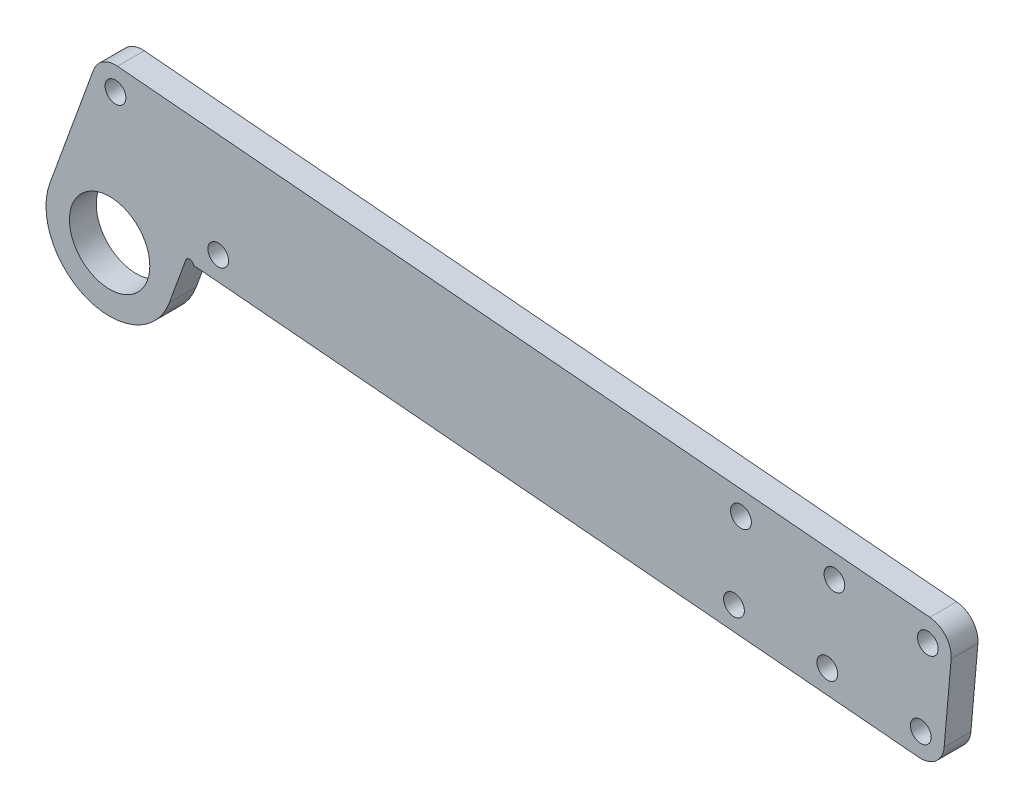
from build123d import *

# Parameters (mm, degrees)
SKETCH_1_R          = 6
EXTRUDE_1_DEPTH     = 2
SKETCH_2_R          = 1.55
SKETCH_2_R_2        = 0.6
CUT_EXTRUDE_1_DEPTH = 5
FILLET_1_R          = 3.5
CUT_EXTRUDE_2_DEPTH = 5
SKETCH_4_R          = 1.55
CUT_EXTRUDE_3_DEPTH = 5
FILLET_2_R          = 3.5


with BuildPart() as part:
    # 草图1 → 凸台-拉伸1 (new body, symmetric)
    with BuildSketch(Plane.XY):
        with BuildLine():
            Line((-8.927079897, 3.249191362), (-1.4961968, 23.665374879))
            Line((-1.4961968, 23.665374879), (160.827979556, 9.463849632))
            ThreePointArc((160.827979556, 9.463849632), (169.463849632, -0.827979556), (159.172020444, -9.463849632))
            Line((159.172020444, -9.463849632), (11.371578553, 3.467013498))
            Line((11.371578553, 3.467013498), (8.927079897, -3.249191362))
            ThreePointArc((8.927079897, -3.249191362), (-3.249191362, -8.927079897), (-8.927079897, 3.249191362))
        make_face()
        Circle(SKETCH_1_R, mode=Mode.SUBTRACT)
        with Locations((160, 0)):
            Circle(SKETCH_1_R, mode=Mode.SUBTRACT)
    extrude(amount=EXTRUDE_1_DEPTH, both=True)

    # 草图2 → 切除-拉伸1 (cut, through all)
    with BuildSketch(Plane.XY.offset(2)):
        with Locations((0.874182871, 19.944624098)):
            Circle(SKETCH_2_R)
        with Locations((16.220555377, 6.556152427)):
            Circle(SKETCH_2_R)
        with Locations((11.935394126, 3.261801412)):
            Circle(SKETCH_2_R_2)
    extrude(amount=-CUT_EXTRUDE_1_DEPTH, mode=Mode.SUBTRACT)

    # 圆角1
    fillet_1_edges = [part.edges().sort_by_distance(p)[0] for p in [
        (-1.4961968, 23.665374879, 0),
    ]]
    fillet(fillet_1_edges, radius=FILLET_1_R)

    # 草图3 → 切除-拉伸2 (cut, through all)
    with BuildSketch(Plane.XY.offset(2)):
        with BuildLine():
            Line((125.961165123, 12.514300628), (124.305206011, -6.413398636))
            Line((124.305206011, -6.413398636), (159.172020444, -9.463849632))
            ThreePointArc((159.172020444, -9.463849632), (169.463849632, -0.827979556), (160.827979556, 9.463849632))
            Line((160.827979556, 9.463849632), (125.961165123, 12.514300628))
        make_face()
    extrude(amount=-CUT_EXTRUDE_2_DEPTH, mode=Mode.SUBTRACT)

    # 草图4 → 切除-拉伸3 (cut, through all)
    with BuildSketch(Plane.XY.offset(2)):
        with Locations((122.16943858, 9.332664284)):
            Circle(SKETCH_4_R)
        with Locations((121.123569667, -2.621672093)):
            Circle(SKETCH_4_R)
        with Locations((94.275987033, 11.773025081)):
            Circle(SKETCH_4_R)
        with Locations((93.23011812, -0.181311296)):
            Circle(SKETCH_4_R)
        with Locations((108.222712807, 10.552844683)):
            Circle(SKETCH_4_R)
        with Locations((107.176843894, -1.401491694)):
            Circle(SKETCH_4_R)
    extrude(amount=-CUT_EXTRUDE_3_DEPTH, mode=Mode.SUBTRACT)

    # 圆角2
    fillet_2_edges = [part.edges().sort_by_distance(p)[0] for p in [
        (125.961165123, 12.514300628, 0),
        (124.305206011, -6.413398636, 0),
    ]]
    fillet(fillet_2_edges, radius=FILLET_2_R)


solid = part.part
